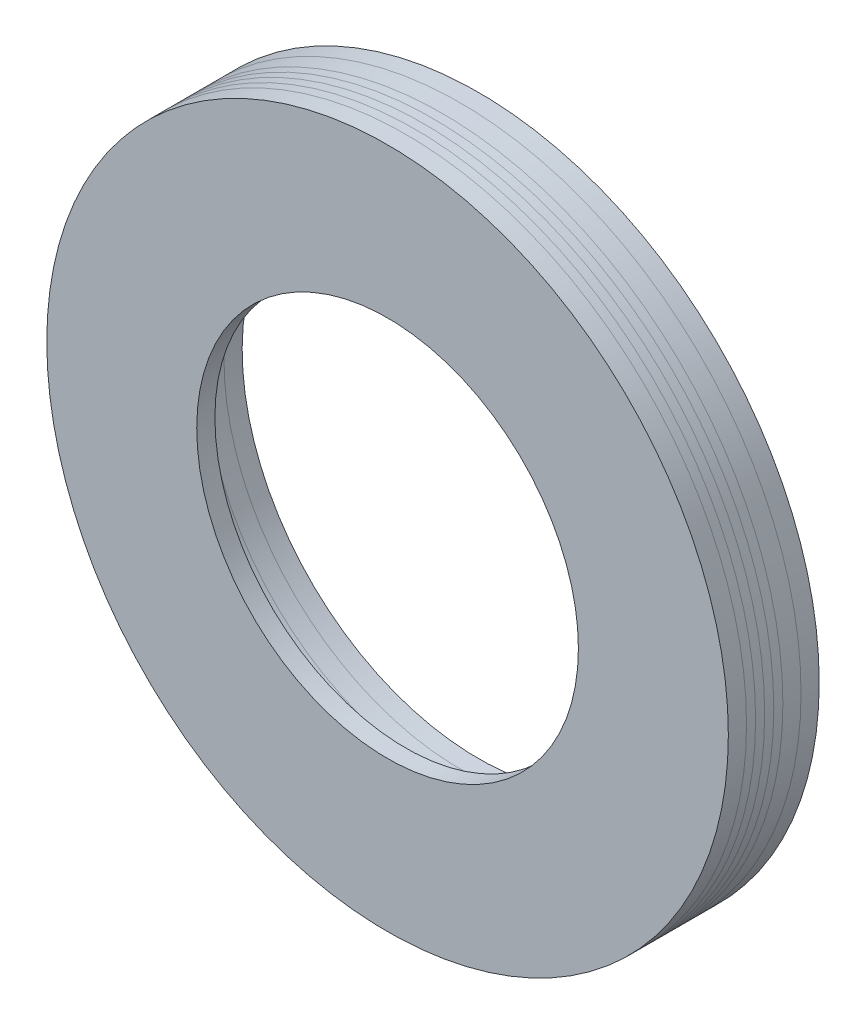
from build123d import *

# Parameters (mm, degrees)
SKETCH_1_R                        = 18.75
EXTRUDE_1_DEPTH                   = 4
SPLIT_BODIES_1_SURFACE_3_1_BACK   = 54.184
SPLIT_BODIES_1_SURFACE_3_1_DEPTH  = 108.368
SPLIT_BODIES_1_SURFACE_3_2_BACK   = 54.184
SPLIT_BODIES_1_SURFACE_3_2_DEPTH  = 108.368
SPLIT_BODIES_1_SURFACE_4_3_BACK   = 54.184
SPLIT_BODIES_1_SURFACE_4_3_DEPTH  = 108.368
SPLIT_BODIES_1_SURFACE_4_4_BACK   = 54.184
SPLIT_BODIES_1_SURFACE_4_4_DEPTH  = 108.368
SPLIT_BODIES_1_SURFACE_5_5_BACK   = 54.184
SPLIT_BODIES_1_SURFACE_5_5_DEPTH  = 108.368
SPLIT_BODIES_1_SURFACE_5_6_BACK   = 54.184
SPLIT_BODIES_1_SURFACE_5_6_DEPTH  = 108.368
SPLIT_BODIES_1_SURFACE_6_7_BACK   = 54.184
SPLIT_BODIES_1_SURFACE_6_7_DEPTH  = 108.368
SPLIT_BODIES_1_SURFACE_6_8_BACK   = 54.184
SPLIT_BODIES_1_SURFACE_6_8_DEPTH  = 108.368
SPLIT_BODIES_1_SURFACE_7_9_BACK   = 54.184
SPLIT_BODIES_1_SURFACE_7_9_DEPTH  = 108.368
SPLIT_BODIES_1_SURFACE_7_10_BACK  = 54.184
SPLIT_BODIES_1_SURFACE_7_10_DEPTH = 108.368
SKETCH_3_R                        = 18.75
SKETCH_3_R_2                      = 10.5
EXTRUDE_2_DEPTH                   = 1


with BuildPart() as part:
    # Эскиз1 → Вытянуть1 (new body)
    with BuildSketch(Plane.XY):
        Circle(SKETCH_1_R)
        with BuildLine():
            Line((-4.5, 16.5), (4.5, 16.5))
            Line((4.5, 16.5), (4.5, 12.196310918))
            ThreePointArc((4.5, 12.196310918), (0, -13), (-4.5, 12.196310918))
            Line((-4.5, 12.196310918), (-4.5, 16.5))
        make_face(mode=Mode.SUBTRACT)
    extrude(amount=EXTRUDE_1_DEPTH)


with BuildPart() as body_2_3:
    # Split Bodies 1 3: the piece behind the surface
    add(part.part)
    # Split Bodies 1 surface 3: a surface, the sketch's curves swept straight by 108.368 mm
    with BuildLine(Plane(origin=(0, 0, 0), x_dir=(1, 0, 0), z_dir=(0, 1, 0)).offset(-SPLIT_BODIES_1_SURFACE_3_1_BACK), mode=Mode.PRIVATE) as split_bodies_1_surface_3_1_path:
        Line((-18.75, -1), (18.75, -1))
    split_bodies_1_surface_3_1 = Shell.extrude(split_bodies_1_surface_3_1_path.wire(), (0 * SPLIT_BODIES_1_SURFACE_3_1_DEPTH, 1 * SPLIT_BODIES_1_SURFACE_3_1_DEPTH, 0 * SPLIT_BODIES_1_SURFACE_3_1_DEPTH))
    split(bisect_by=split_bodies_1_surface_3_1, keep=Keep.BOTTOM)


with BuildPart() as part_1:
    add(part.part)

    # Split Bodies 1 3: split by a surface, the side it looks to stays
    # Split Bodies 1 surface 3: a surface, the sketch's curves swept straight by 108.368 mm
    with BuildLine(Plane(origin=(0, 0, 0), x_dir=(1, 0, 0), z_dir=(0, 1, 0)).offset(-SPLIT_BODIES_1_SURFACE_3_2_BACK), mode=Mode.PRIVATE) as split_bodies_1_surface_3_2_path:
        Line((-18.75, -1), (18.75, -1))
    split_bodies_1_surface_3_2 = Shell.extrude(split_bodies_1_surface_3_2_path.wire(), (0 * SPLIT_BODIES_1_SURFACE_3_2_DEPTH, 1 * SPLIT_BODIES_1_SURFACE_3_2_DEPTH, 0 * SPLIT_BODIES_1_SURFACE_3_2_DEPTH))
    split(bisect_by=split_bodies_1_surface_3_2, keep=Keep.TOP)


with BuildPart() as body_3:
    # Split Bodies 1 4 body 2 3: the piece behind the surface
    add(body_2_3.part)
    # Split Bodies 1 surface 4: a surface, the sketch's curves swept straight by 108.368 mm
    with BuildLine(Plane(origin=(0, 0, 0), x_dir=(1, 0, 0), z_dir=(0, 1, 0)).offset(-SPLIT_BODIES_1_SURFACE_4_3_BACK), mode=Mode.PRIVATE) as split_bodies_1_surface_4_3_path:
        Line((-18.75, -2), (18.75, -2))
    split_bodies_1_surface_4_3 = Shell.extrude(split_bodies_1_surface_4_3_path.wire(), (0 * SPLIT_BODIES_1_SURFACE_4_3_DEPTH, 1 * SPLIT_BODIES_1_SURFACE_4_3_DEPTH, 0 * SPLIT_BODIES_1_SURFACE_4_3_DEPTH))
    split(bisect_by=split_bodies_1_surface_4_3, keep=Keep.BOTTOM)


with BuildPart() as body_2_3_1:
    add(body_2_3.part)

    # Split Bodies 1 4 body 2 3: split by a surface, the side it looks to stays
    # Split Bodies 1 surface 4: a surface, the sketch's curves swept straight by 108.368 mm
    with BuildLine(Plane(origin=(0, 0, 0), x_dir=(1, 0, 0), z_dir=(0, 1, 0)).offset(-SPLIT_BODIES_1_SURFACE_4_4_BACK), mode=Mode.PRIVATE) as split_bodies_1_surface_4_4_path:
        Line((-18.75, -2), (18.75, -2))
    split_bodies_1_surface_4_4 = Shell.extrude(split_bodies_1_surface_4_4_path.wire(), (0 * SPLIT_BODIES_1_SURFACE_4_4_DEPTH, 1 * SPLIT_BODIES_1_SURFACE_4_4_DEPTH, 0 * SPLIT_BODIES_1_SURFACE_4_4_DEPTH))
    split(bisect_by=split_bodies_1_surface_4_4, keep=Keep.TOP)


with BuildPart() as body_4:
    # Split Bodies 1 5 body 3: the piece behind the surface
    add(body_3.part)
    # Split Bodies 1 surface 5: a surface, the sketch's curves swept straight by 108.368 mm
    with BuildLine(Plane(origin=(0, 0, 0), x_dir=(1, 0, 0), z_dir=(0, 1, 0)).offset(-SPLIT_BODIES_1_SURFACE_5_5_BACK), mode=Mode.PRIVATE) as split_bodies_1_surface_5_5_path:
        Line((-18.75, -2.5), (18.75, -2.5))
    split_bodies_1_surface_5_5 = Shell.extrude(split_bodies_1_surface_5_5_path.wire(), (0 * SPLIT_BODIES_1_SURFACE_5_5_DEPTH, 1 * SPLIT_BODIES_1_SURFACE_5_5_DEPTH, 0 * SPLIT_BODIES_1_SURFACE_5_5_DEPTH))
    split(bisect_by=split_bodies_1_surface_5_5, keep=Keep.BOTTOM)


with BuildPart() as body_3_1:
    add(body_3.part)

    # Split Bodies 1 5 body 3: split by a surface, the side it looks to stays
    # Split Bodies 1 surface 5: a surface, the sketch's curves swept straight by 108.368 mm
    with BuildLine(Plane(origin=(0, 0, 0), x_dir=(1, 0, 0), z_dir=(0, 1, 0)).offset(-SPLIT_BODIES_1_SURFACE_5_6_BACK), mode=Mode.PRIVATE) as split_bodies_1_surface_5_6_path:
        Line((-18.75, -2.5), (18.75, -2.5))
    split_bodies_1_surface_5_6 = Shell.extrude(split_bodies_1_surface_5_6_path.wire(), (0 * SPLIT_BODIES_1_SURFACE_5_6_DEPTH, 1 * SPLIT_BODIES_1_SURFACE_5_6_DEPTH, 0 * SPLIT_BODIES_1_SURFACE_5_6_DEPTH))
    split(bisect_by=split_bodies_1_surface_5_6, keep=Keep.TOP)


with BuildPart() as body_5:
    # Split Bodies 1 6 body 4: the piece behind the surface
    add(body_4.part)
    # Split Bodies 1 surface 6: a surface, the sketch's curves swept straight by 108.368 mm
    with BuildLine(Plane(origin=(0, 0, 0), x_dir=(1, 0, 0), z_dir=(0, 1, 0)).offset(-SPLIT_BODIES_1_SURFACE_6_7_BACK), mode=Mode.PRIVATE) as split_bodies_1_surface_6_7_path:
        Line((-18.75, -3), (18.75, -3))
    split_bodies_1_surface_6_7 = Shell.extrude(split_bodies_1_surface_6_7_path.wire(), (0 * SPLIT_BODIES_1_SURFACE_6_7_DEPTH, 1 * SPLIT_BODIES_1_SURFACE_6_7_DEPTH, 0 * SPLIT_BODIES_1_SURFACE_6_7_DEPTH))
    split(bisect_by=split_bodies_1_surface_6_7, keep=Keep.BOTTOM)


with BuildPart() as body_4_1:
    add(body_4.part)

    # Split Bodies 1 6 body 4: split by a surface, the side it looks to stays
    # Split Bodies 1 surface 6: a surface, the sketch's curves swept straight by 108.368 mm
    with BuildLine(Plane(origin=(0, 0, 0), x_dir=(1, 0, 0), z_dir=(0, 1, 0)).offset(-SPLIT_BODIES_1_SURFACE_6_8_BACK), mode=Mode.PRIVATE) as split_bodies_1_surface_6_8_path:
        Line((-18.75, -3), (18.75, -3))
    split_bodies_1_surface_6_8 = Shell.extrude(split_bodies_1_surface_6_8_path.wire(), (0 * SPLIT_BODIES_1_SURFACE_6_8_DEPTH, 1 * SPLIT_BODIES_1_SURFACE_6_8_DEPTH, 0 * SPLIT_BODIES_1_SURFACE_6_8_DEPTH))
    split(bisect_by=split_bodies_1_surface_6_8, keep=Keep.TOP)


with BuildPart() as body_6:
    # Split Bodies 1 7 body 5: the piece behind the surface
    add(body_5.part)
    # Split Bodies 1 surface 7: a surface, the sketch's curves swept straight by 108.368 mm
    with BuildLine(Plane(origin=(0, 0, 0), x_dir=(1, 0, 0), z_dir=(0, 1, 0)).offset(-SPLIT_BODIES_1_SURFACE_7_9_BACK), mode=Mode.PRIVATE) as split_bodies_1_surface_7_9_path:
        Line((-18.75, -3.5), (18.75, -3.5))
    split_bodies_1_surface_7_9 = Shell.extrude(split_bodies_1_surface_7_9_path.wire(), (0 * SPLIT_BODIES_1_SURFACE_7_9_DEPTH, 1 * SPLIT_BODIES_1_SURFACE_7_9_DEPTH, 0 * SPLIT_BODIES_1_SURFACE_7_9_DEPTH))
    split(bisect_by=split_bodies_1_surface_7_9, keep=Keep.BOTTOM)


with BuildPart() as body_5_1:
    add(body_5.part)

    # Split Bodies 1 7 body 5: split by a surface, the side it looks to stays
    # Split Bodies 1 surface 7: a surface, the sketch's curves swept straight by 108.368 mm
    with BuildLine(Plane(origin=(0, 0, 0), x_dir=(1, 0, 0), z_dir=(0, 1, 0)).offset(-SPLIT_BODIES_1_SURFACE_7_10_BACK), mode=Mode.PRIVATE) as split_bodies_1_surface_7_10_path:
        Line((-18.75, -3.5), (18.75, -3.5))
    split_bodies_1_surface_7_10 = Shell.extrude(split_bodies_1_surface_7_10_path.wire(), (0 * SPLIT_BODIES_1_SURFACE_7_10_DEPTH, 1 * SPLIT_BODIES_1_SURFACE_7_10_DEPTH, 0 * SPLIT_BODIES_1_SURFACE_7_10_DEPTH))
    split(bisect_by=split_bodies_1_surface_7_10, keep=Keep.TOP)


with BuildPart() as body_7:
    # Эскиз3 → Вытянуть2 (new body)
    with BuildSketch(Plane.XY.offset(4)):
        Circle(SKETCH_3_R)
        Circle(SKETCH_3_R_2, mode=Mode.SUBTRACT)
    extrude(amount=EXTRUDE_2_DEPTH)


solid = Compound([part_1.part, body_2_3_1.part, body_3_1.part, body_4_1.part, body_6.part, body_5_1.part, body_7.part])
